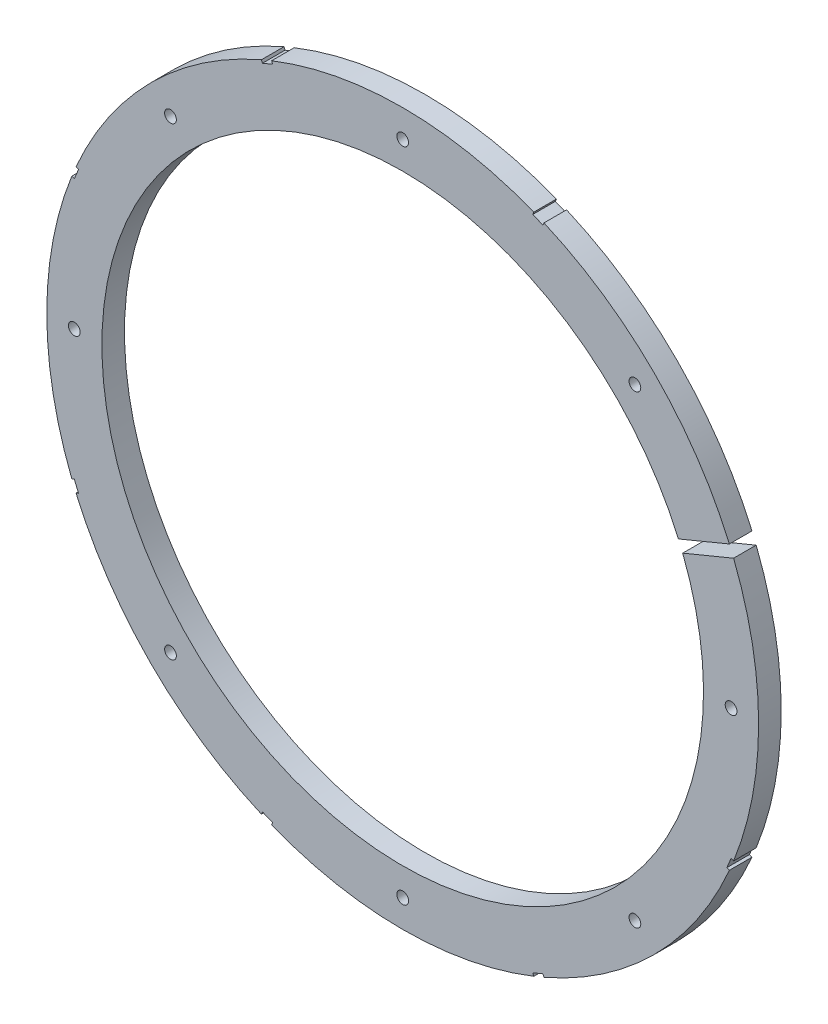
from build123d import *

# Parameters (mm, degrees)
SKETCH4_R             = 82.042
BOSS_EXTRUDE2_DEPTH   = 5.207
SKETCH5_R             = 69.342
CUT_EXTRUDE5_DEPTH    = 6.207
CUT_EXTRUDE11_DEPTH   = 6.207
F_6_32_TAPPED_HOLE1_D = 2.7051


with BuildPart() as part:
    # Sketch4 → Boss-Extrude2 (new body)
    with BuildSketch(Plane.XY):
        Circle(SKETCH4_R)
    extrude(amount=BOSS_EXTRUDE2_DEPTH)

    # Sketch5 → Cut-Extrude5 (cut, through all)
    with BuildSketch(Plane.XY.offset(5.207)):
        Circle(SKETCH5_R)
    extrude(amount=-CUT_EXTRUDE5_DEPTH, mode=Mode.SUBTRACT)

    # Sketch8 → Cut-Extrude11 (cut, through all)
    with BuildSketch(Plane.XY.offset(5.207)):
        Polygon((81.764215182, 35.242484939), (62.990983081, 27.466357594), (63.962998999, 25.119703581), (82.7362311, 32.895830927), align=None)
        Polygon((32.812445144, 75.89758015), (30.465791131, 76.869596069), (29.979783172, 75.696269062), (32.326437185, 74.724253144), align=None)
        Polygon((-30.465791131, 76.869596069), (-32.812445144, 75.89758015), (-32.326437185, 74.724253144), (-29.979783172, 75.696269062), align=None)
        Polygon((-75.89758015, 32.812445144), (-76.869596069, 30.465791131), (-75.696269062, 29.979783172), (-74.724253144, 32.326437185), align=None)
        Polygon((-76.869596069, -30.465791131), (-75.89758015, -32.812445144), (-74.724253144, -32.326437185), (-75.696269062, -29.979783172), align=None)
        Polygon((-32.812445144, -75.89758015), (-30.465791131, -76.869596069), (-29.979783172, -75.696269062), (-32.326437185, -74.724253144), align=None)
        Polygon((30.465791131, -76.869596069), (32.812445144, -75.89758015), (32.326437185, -74.724253144), (29.979783172, -75.696269062), align=None)
        Polygon((75.89758015, -32.812445144), (76.869596069, -30.465791131), (75.696269062, -29.979783172), (74.724253144, -32.326437185), align=None)
    extrude(amount=-CUT_EXTRUDE11_DEPTH, mode=Mode.SUBTRACT)

    # #6-32 Tapped Hole1 (through all)
    with Locations(Plane.XY.offset(5.207)):
        with Locations((75.692, 0), (53.522326482, -53.522326482), (0, -75.692), (-53.522326482, -53.522326482), (-75.692, 0), (-53.522326482, 53.522326482), (0, 75.692), (53.522326482, 53.522326482)):
            Hole(F_6_32_TAPPED_HOLE1_D / 2)


solid = part.part
